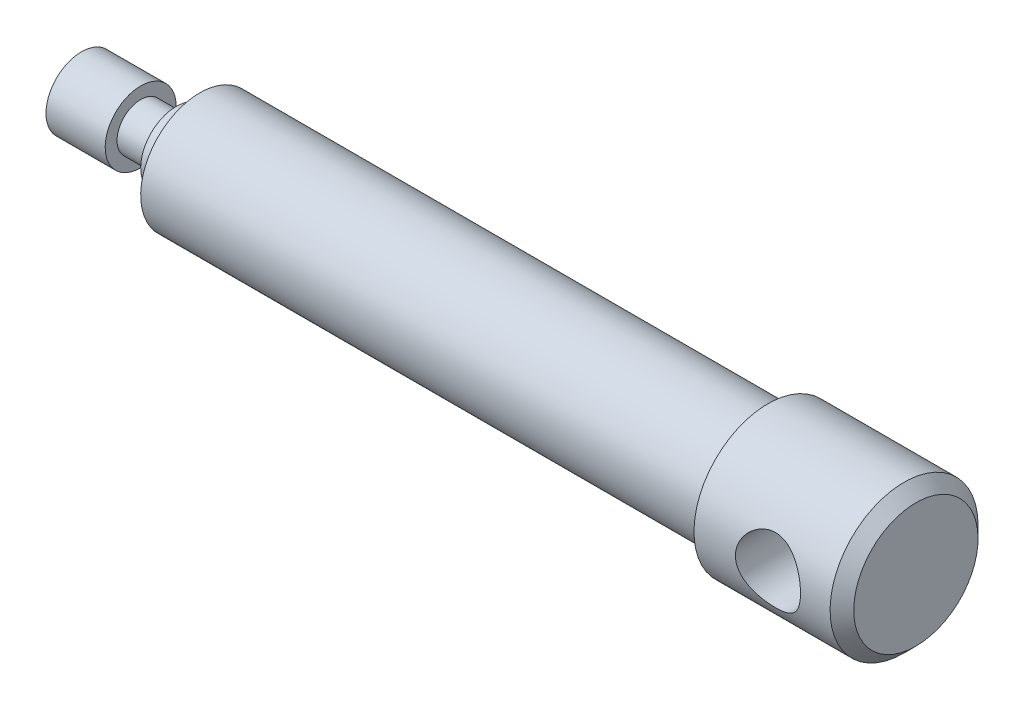
from build123d import *

# Parameters (mm, degrees)
SKETCH1_W          = 25
SKETCH1_H          = 12.5
SKETCH1_W_2        = 6
SKETCH1_H_2        = 4
SKETCH2_R          = 5.5
CUT_EXTRUDE1_DEPTH = 15
CHAMFER1_SIZE      = 2


with BuildPart() as part:
    # Sketch1 → Revolve3 (revolve)
    with BuildSketch(Plane.XY):
        with Locations((0, 6.25)):
            Rectangle(SKETCH1_W, SKETCH1_H)
        Polygon((-12.5, 0), (-12.5, 10), (-108.5, 10), (-108.5, 6), (-108.5, 0), align=None)
        Polygon((-108.5, 0), (-108.5, 6), (-112.5, 6), (-112.5, 4), (-112.5, 0), align=None)
        with Locations((-115.5, 2)):
            Rectangle(SKETCH1_W_2, SKETCH1_H_2)
        Polygon((-128.5, 6), (-128.5, 0), (-118.5, 0), (-118.5, 4), (-118.5, 6), align=None)
        Polygon((-128.5, 6), (-131.964101615, 0), (-128.5, 0), align=None)
    revolve(axis=Axis((-108.5, 0, 0), (1, 0, 0)))

    # Sketch2 → Cut-Extrude1 (cut, symmetric)
    with BuildSketch(Plane.XY):
        Circle(SKETCH2_R)
    extrude(amount=CUT_EXTRUDE1_DEPTH, both=True, mode=Mode.SUBTRACT)

    # Chamfer1
    chamfer1_edges = [part.edges().sort_by_distance(p)[0] for p in [
        (12.5, -12.5, 0),
    ]]
    chamfer(chamfer1_edges, length=CHAMFER1_SIZE)


solid = part.part
